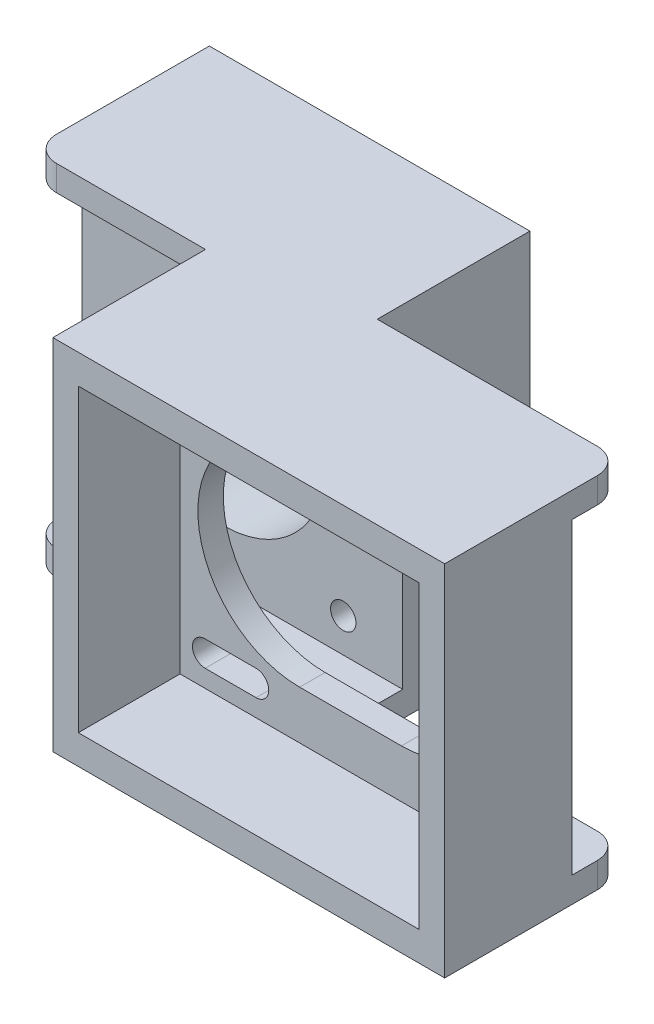
from build123d import *

# Parameters (mm, degrees)
SKETCH1_W           = 77
SKETCH1_H           = 20
SKETCH1_W_2         = 118.75
SKETCH1_H_2         = 25
SKETCH1_W_3         = 70.5
BOSS_EXTRUDE1_DEPTH = 70.5
SKETCH6_W           = 15
SKETCH6_H           = 60.5
CUT_EXTRUDE2_DEPTH  = 48.25
SKETCH7_W           = 67
SKETCH7_H           = 59
CUT_EXTRUDE3_DEPTH  = 20
CUT_EXTRUDE4_DEPTH  = 5
SKETCH9_W           = 5
SKETCH9_H           = 60.5
CUT_EXTRUDE5_DEPTH  = 48.25
SKETCH10_W          = 15
SKETCH10_H          = 60.5
CUT_EXTRUDE6_DEPTH  = 70.5
SKETCH11_W          = 5
SKETCH11_H          = 60.5
CUT_EXTRUDE7_DEPTH  = 41.75
SKETCH12_W          = 60.5
SKETCH12_H          = 60.5
CUT_EXTRUDE8_DEPTH  = 15
SKETCH13_R          = 20
SKETCH13_R_2        = 2.5
CUT_EXTRUDE9_DEPTH  = 20
SKETCH14_W          = 7.5
SKETCH14_H          = 35
SKETCH14_H_2        = 10
SKETCH14_W_2        = 34.25
SKETCH14_W_3        = 48.25
CUT_EXTRUDE10_DEPTH = 71.5
FILLET2_R           = 5


with BuildPart() as part:
    # Sketch1 → Boss-Extrude1 (new body)
    with BuildSketch(Plane(origin=(0, 0, 0), x_dir=(1, 0, 0), z_dir=(0, 1, 0))):
        with Locations((20.875, -22.5)):
            Rectangle(SKETCH1_W, SKETCH1_H)
        Rectangle(SKETCH1_W_2, SKETCH1_H_2)
        with Locations((-24.125, 22.5)):
            Rectangle(SKETCH1_W_3, SKETCH1_H)
    extrude(amount=BOSS_EXTRUDE1_DEPTH)

    # Sketch6 → Cut-Extrude2 (cut)
    with BuildSketch(Plane(origin=(59.375, 0, 0), x_dir=(0, 0, -1), z_dir=(1, 0, 0))):
        with Locations((0, 35.25)):
            Rectangle(SKETCH6_W, SKETCH6_H)
    extrude(amount=-CUT_EXTRUDE2_DEPTH, mode=Mode.SUBTRACT)

    # Sketch7 → Cut-Extrude3 (cut)
    with BuildSketch(Plane.XY.offset(32.5)):
        with Locations((20.875, 35.25)):
            Rectangle(SKETCH7_W, SKETCH7_H)
    extrude(amount=-CUT_EXTRUDE3_DEPTH, mode=Mode.SUBTRACT)

    # Sketch8 → Cut-Extrude4 (cut)
    with BuildSketch(Plane.XY.offset(12.5)):
        with BuildLine():
            Line((10.875, 55.25), (30.875, 55.25))
            ThreePointArc((30.875, 55.25), (50.875, 35.25), (30.875, 15.25))
            Line((30.875, 15.25), (10.875, 15.25))
            ThreePointArc((10.875, 15.25), (-9.125, 35.25), (10.875, 55.25))
        make_face()
        with BuildLine():
            Line((-7.695, 61.32), (2.305, 61.32))
            ThreePointArc((2.305, 61.32), (4.805, 58.82), (2.305, 56.32))
            Line((2.305, 56.32), (-7.695, 56.32))
            ThreePointArc((-7.695, 56.32), (-10.195, 58.82), (-7.695, 61.32))
        make_face()
        with BuildLine():
            Line((49.445, 61.32), (39.445, 61.32))
            ThreePointArc((39.445, 61.32), (36.945, 58.82), (39.445, 56.32))
            Line((39.445, 56.32), (49.445, 56.32))
            ThreePointArc((49.445, 56.32), (51.945, 58.82), (49.445, 61.32))
        make_face()
        with BuildLine():
            Line((-7.695, 9.18), (2.305, 9.18))
            ThreePointArc((2.305, 9.18), (4.805, 11.68), (2.305, 14.18))
            Line((2.305, 14.18), (-7.695, 14.18))
            ThreePointArc((-7.695, 14.18), (-10.195, 11.68), (-7.695, 9.18))
        make_face()
        with BuildLine():
            Line((49.445, 9.18), (39.445, 9.18))
            ThreePointArc((39.445, 9.18), (36.945, 11.68), (39.445, 14.18))
            Line((39.445, 14.18), (49.445, 14.18))
            ThreePointArc((49.445, 14.18), (51.945, 11.68), (49.445, 9.18))
        make_face()
    extrude(amount=-CUT_EXTRUDE4_DEPTH, mode=Mode.SUBTRACT)

    # Sketch9 → Cut-Extrude5 (cut)
    with BuildSketch(Plane(origin=(59.375, 0, 0), x_dir=(0, 0, -1), z_dir=(1, 0, 0))):
        with Locations((10, 35.25)):
            Rectangle(SKETCH9_W, SKETCH9_H)
    extrude(amount=-CUT_EXTRUDE5_DEPTH, mode=Mode.SUBTRACT)

    # Sketch10 → Cut-Extrude6 (cut)
    with BuildSketch(Plane.ZY.offset(59.375)):
        with Locations((0, 35.25)):
            Rectangle(SKETCH10_W, SKETCH10_H)
    extrude(amount=-CUT_EXTRUDE6_DEPTH, mode=Mode.SUBTRACT)

    # Sketch11 → Cut-Extrude7 (cut)
    with BuildSketch(Plane.ZY.offset(59.375)):
        with Locations((10, 35.25)):
            Rectangle(SKETCH11_W, SKETCH11_H)
    extrude(amount=-CUT_EXTRUDE7_DEPTH, mode=Mode.SUBTRACT)

    # Sketch12 → Cut-Extrude8 (cut)
    with BuildSketch(Plane(origin=(0, 0, -32.5), x_dir=(-1, 0, 0), z_dir=(0, 0, -1))):
        with Locations((24.125, 35.25)):
            Rectangle(SKETCH12_W, SKETCH12_H)
    extrude(amount=-CUT_EXTRUDE8_DEPTH, mode=Mode.SUBTRACT)

    # Sketch13 → Cut-Extrude9 (cut)
    with BuildSketch(Plane(origin=(0, 0, -17.5), x_dir=(-1, 0, 0), z_dir=(0, 0, -1))):
        with Locations((24.125, 35.25)):
            Circle(SKETCH13_R)
        with Locations((0.555, 58.82)):
            Circle(SKETCH13_R_2)
        with Locations((47.695, 58.82)):
            Circle(SKETCH13_R_2)
        with Locations((47.695, 11.68)):
            Circle(SKETCH13_R_2)
        with Locations((0.555, 11.68)):
            Circle(SKETCH13_R_2)
    extrude(amount=-CUT_EXTRUDE9_DEPTH, mode=Mode.SUBTRACT)

    # Sketch14 → Cut-Extrude10 (cut, through all)
    with BuildSketch(Plane(origin=(0, 70.5, 0), x_dir=(1, 0, 0), z_dir=(0, 1, 0))):
        with Locations((-55.625, 15)):
            Rectangle(SKETCH14_W, SKETCH14_H)
        with Locations((-55.625, -7.5)):
            Rectangle(SKETCH14_W, SKETCH14_H_2)
        with Locations((-34.75, -7.5)):
            Rectangle(SKETCH14_W_2, SKETCH14_H_2)
        with Locations((35.25, 7.5)):
            Rectangle(SKETCH14_W_3, SKETCH14_H_2)
    extrude(amount=-CUT_EXTRUDE10_DEPTH, mode=Mode.SUBTRACT)

    # Fillet2
    fillet2_edges = [part.edges().sort_by_distance(p)[0] for p in [
        (-51.875, 68, 2.5),
        (-51.875, 2.5, 2.5),
        (59.375, 68, -2.5),
        (59.375, 2.5, -2.5),
    ]]
    fillet(fillet2_edges, radius=FILLET2_R)


solid = part.part
